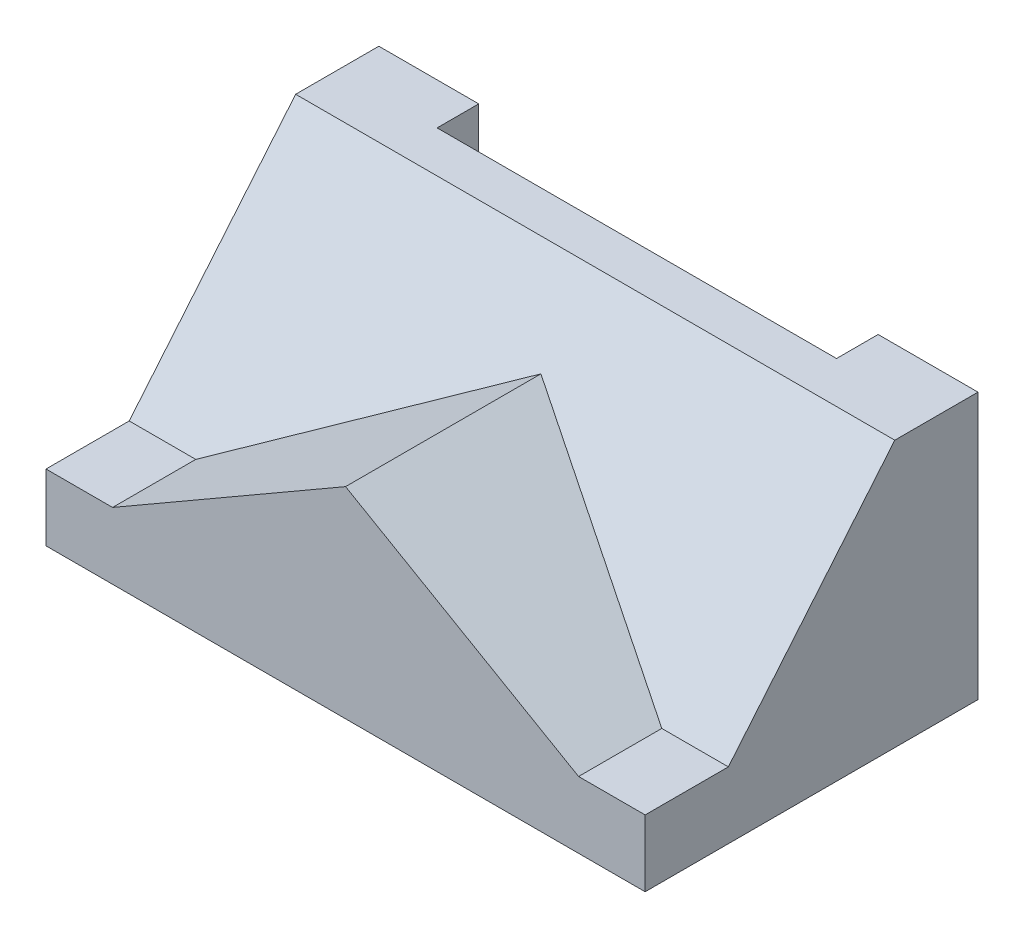
from build123d import *

# Parameters (mm, degrees)
BOSS_EXTRUDE1_DEPTH = 57.15
BOSS_EXTRUDE2_REACH = 65.5
CUT_EXTRUDE1_REACH  = 52.8
SKETCH4_W           = 76.2
SKETCH4_H           = 7.9375


with BuildPart() as part:
    # Sketch2 → Boss-Extrude1 (new body, symmetric)
    with BuildSketch(Plane(origin=(0, 0, 0), x_dir=(0, 0, -1), z_dir=(1, 0, 0))):
        Polygon((-63.5, 0), (0, 0), (0, 50.8), (-15.875, 50.8), (-47.625, 12.7), (-63.5, 12.7), align=None)
    extrude(amount=BOSS_EXTRUDE1_DEPTH, both=True)

    # Sketch3 → Boss-Extrude2 (add, up to next)
    with BuildSketch(Plane.XY.offset(63.5), mode=Mode.PRIVATE) as boss_extrude2_sk1:
        Polygon((-44.45, 12.7), (44.45, 12.7), (0, 38.363219465), align=None)
    boss_extrude2_tool1 = extrude(boss_extrude2_sk1.sketch, amount=-BOSS_EXTRUDE2_REACH, mode=Mode.PRIVATE) - part.part
    add(boss_extrude2_tool1.solids().sort_by_distance((0, 21.254406, 63.5))[0])

    # Sketch4 → Cut-Extrude1 (cut, up to next)
    with BuildSketch(Plane(origin=(0, 50.8, 0), x_dir=(1, 0, 0), z_dir=(0, 1, 0)), mode=Mode.PRIVATE) as cut_extrude1_sk1:
        with Locations((0, -3.96875)):
            Rectangle(SKETCH4_W, SKETCH4_H)
    cut_extrude1_tool1 = extrude(cut_extrude1_sk1.sketch, amount=-CUT_EXTRUDE1_REACH, mode=Mode.PRIVATE) & part.part
    add(cut_extrude1_tool1.solids().sort_by_distance((0, 50.8, 3.96875))[0], mode=Mode.SUBTRACT)


solid = part.part
